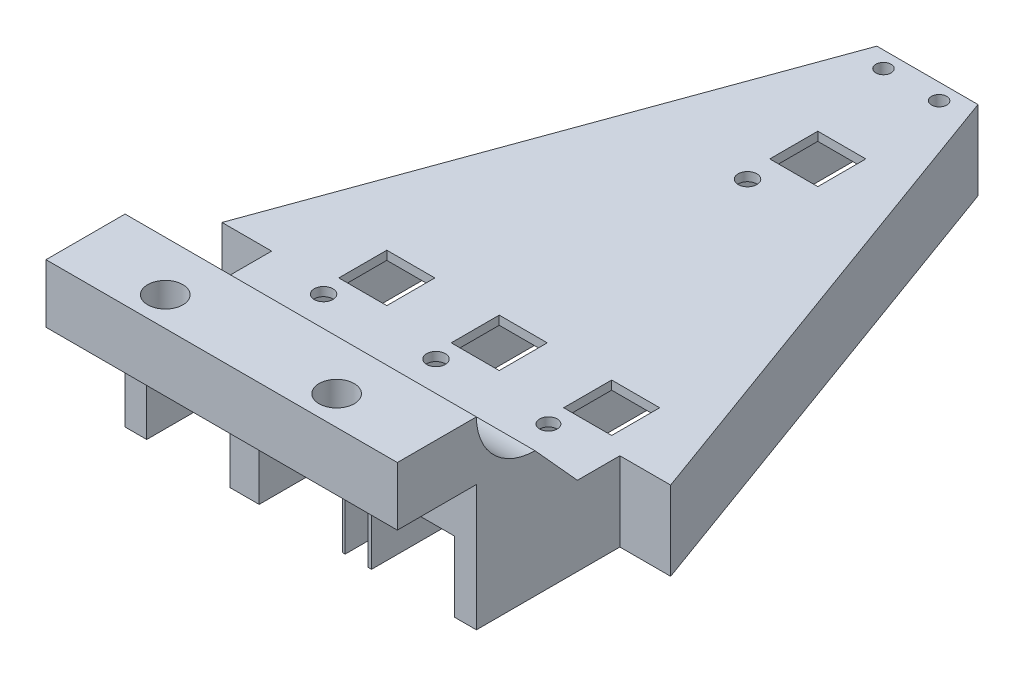
from build123d import *

# Parameters (mm, degrees)
SKETCH2_W           = 60
SKETCH2_H           = 13.5
SKETCH2_R           = 1.75
BOSS_EXTRUDE1_DEPTH = 10
BOSS_EXTRUDE2_DEPTH = 21.5
BOSS_EXTRUDE3_DEPTH = 60
SKETCH10_R          = 1.3
CUT_EXTRUDE1_DEPTH  = 22.5
SKETCH12_W          = 14.2
SKETCH12_H          = 32.2
CUT_EXTRUDE2_DEPTH  = 12
CUT_EXTRUDE3_DEPTH  = 12
SKETCH14_R          = 3
CUT_EXTRUDE4_DEPTH  = 6.5
SKETCH15_R          = 1.6
SKETCH15_R_2        = 1.5
SKETCH15_W          = 8.2
SKETCH15_H          = 8.2
CUT_EXTRUDE5_DEPTH  = 22.5
CUT_EXTRUDE6_DEPTH  = 8
BOSS_EXTRUDE4_DEPTH = 60


with BuildPart() as part:
    # Sketch2 → Boss-Extrude1 (new body)
    with BuildSketch(Plane(origin=(0, 0, 0), x_dir=(1, 0, 0), z_dir=(0, 1, 0))):
        with Locations((14.63, 1.75)):
            Rectangle(SKETCH2_W, SKETCH2_H)
        Circle(SKETCH2_R, mode=Mode.SUBTRACT)
        with Locations((29.264, 0)):
            Circle(SKETCH2_R, mode=Mode.SUBTRACT)
    extrude(amount=BOSS_EXTRUDE1_DEPTH)



with BuildPart() as body_2:
    # Sketch5 → Boss-Extrude2 (new body)
    with BuildSketch(Plane(origin=(0, 0, 0), x_dir=(1, 0, 0), z_dir=(0, 1, 0))):
        Polygon((-15.37, 8.5), (-15.37, 33.533725193), (-23.847078232, 33.533725193), (5.995022283, 115.524222507), (23.264977717, 115.524222507), (53.301097121, 33.000662678), (44.63, 33.000662678), (44.63, 8.5), align=None)
    extrude(amount=-BOSS_EXTRUDE2_DEPTH)


with BuildPart() as part_1:
    add(part.part)

    add(body_2.part)  # Boss-Extrude3 merges body 2
    # Sketch8 → Boss-Extrude3 (add)
    with BuildSketch(Plane.ZY.offset(15.37)):
        with BuildLine():
            Line((-18.5, 0), (-8.5, 0))
            Line((-8.5, 0), (-8.5, 10))
            ThreePointArc((-8.5, 10), (-11.428932188, 2.928932188), (-18.5, 0))
        make_face()
    extrude(amount=-BOSS_EXTRUDE3_DEPTH)

    # Sketch10 → Cut-Extrude1 (cut, through all)
    with BuildSketch(Plane(origin=(0, 0, 0), x_dir=(1, 0, 0), z_dir=(0, 1, 0))):
        with Locations((19.38, 112.769736608)):
            Circle(SKETCH10_R)
        with Locations((9.88, 112.769736608)):
            Circle(SKETCH10_R)
    extrude(amount=-CUT_EXTRUDE1_DEPTH, mode=Mode.SUBTRACT)

    # Sketch12 → Cut-Extrude2 (cut)
    with BuildSketch(Plane.XZ.offset(21.5)):
        with Locations((14.63, -93.8)):
            Rectangle(SKETCH12_W, SKETCH12_H)
        with Locations((-4.57, -40.6)):
            Rectangle(SKETCH12_W, SKETCH12_H)
        with Locations((14.63, -40.6)):
            Rectangle(SKETCH12_W, SKETCH12_H)
        with Locations((33.83, -40.6)):
            Rectangle(SKETCH12_W, SKETCH12_H)
    extrude(amount=-CUT_EXTRUDE2_DEPTH, mode=Mode.SUBTRACT)

    # Sketch13 → Cut-Extrude3 (cut)
    with BuildSketch(Plane.XZ.offset(21.5)):
        Polygon((21.73, -77.7), (7.53, -77.7), (7.53, -61.7), (7.53, -57.396998359), (22.223753722, -57.396998359), (22.223753722, -8.5), (21.73, -8.5), (21.73, -24.5), (7.53, -24.5), (7.53, -8.5), (2.53, -8.5), (2.53, -24.5), (-11.67, -24.5), (-11.67, -8.5), (-11.67, -5.014735678), (40.93, -5.014735678), (40.93, -8.5), (40.93, -24.5), (26.73, -24.5), (26.73, -8.5), (26.149155121, -8.5), (26.149155121, -61.7), (21.73, -61.7), align=None)
    extrude(amount=-CUT_EXTRUDE3_DEPTH, mode=Mode.SUBTRACT)

    # Sketch14 → Cut-Extrude4 (cut)
    with BuildSketch(Plane(origin=(0, 10, 0), x_dir=(1, 0, 0), z_dir=(0, 1, 0))):
        Circle(SKETCH14_R)
        with Locations((29.264, 0)):
            Circle(SKETCH14_R)
    extrude(amount=-CUT_EXTRUDE4_DEPTH, mode=Mode.SUBTRACT)

    # Sketch15 → Cut-Extrude5 (cut, through all)
    with BuildSketch(Plane(origin=(0, 0, 0), x_dir=(1, 0, 0), z_dir=(0, 1, 0))):
        with Locations((-4.57, 31.6)):
            Circle(SKETCH15_R)
        with Locations((14.63, 31.6)):
            Circle(SKETCH15_R)
        with Locations((33.83, 31.6)):
            Circle(SKETCH15_R_2)
        with Locations((14.63, 84.8)):
            Circle(SKETCH15_R)
        with Locations((17.63, 93.8)):
            Rectangle(SKETCH15_W, SKETCH15_H)
        with Locations((17.63, 39.4)):
            Rectangle(SKETCH15_W, SKETCH15_H)
        with Locations((36.83, 39.4)):
            Rectangle(SKETCH15_W, SKETCH15_H)
        with Locations((-1.57, 39.4)):
            Rectangle(SKETCH15_W, SKETCH15_H)
    extrude(amount=-CUT_EXTRUDE5_DEPTH, mode=Mode.SUBTRACT)

    # Sketch16 → Cut-Extrude6 (cut)
    with BuildSketch(Plane(origin=(0, 0, 0), x_dir=(1, 0, 0), z_dir=(0, 1, 0))):
        Polygon((-15.37, 18.5), (44.63, 18.5), (44.63, 33.000662678), (53.301097121, 33.000662678), (23.264977717, 115.524222507), (5.995022283, 115.524222507), (-23.847078232, 33.533725193), (-15.37, 33.533725193), align=None)
    extrude(amount=-CUT_EXTRUDE6_DEPTH, mode=Mode.SUBTRACT)

    # Sketch17 → Boss-Extrude4 (add)
    with BuildSketch(Plane(origin=(44.63, 0, 0), x_dir=(0, 0, -1), z_dir=(1, 0, 0))):
        Polygon((18.5, 0), (25.750331339, -8), (18.5, -8), align=None)
    extrude(amount=-BOSS_EXTRUDE4_DEPTH)


solid = part_1.part
